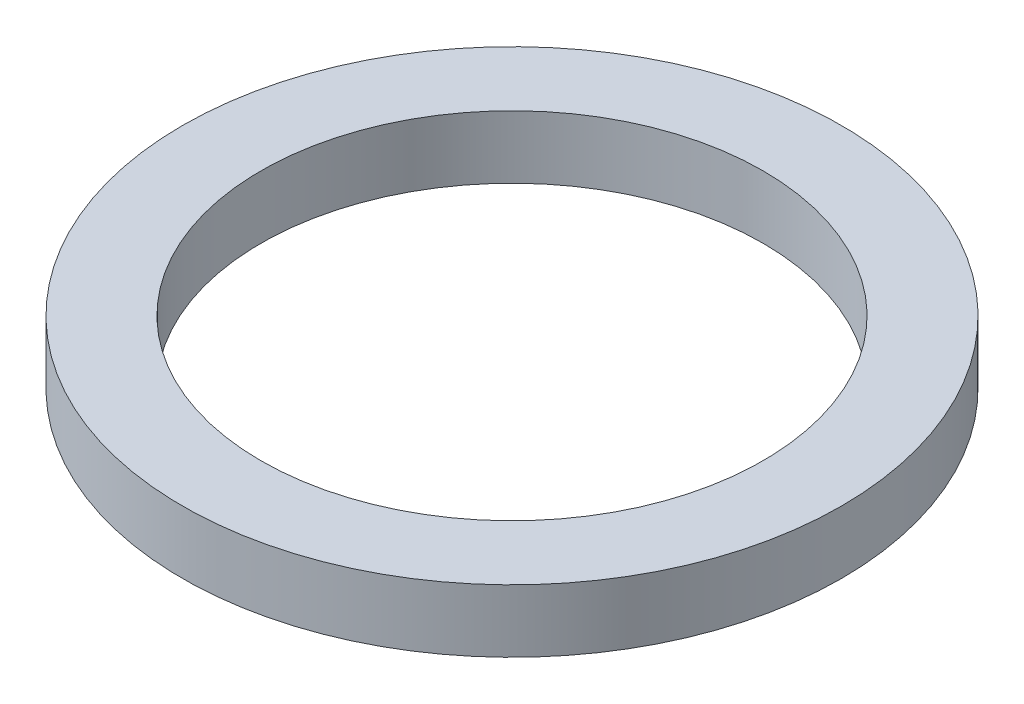
from build123d import *

# Parameters (mm, degrees)
SKETCH1_R           = 5.25
SKETCH1_R_2         = 4
EXTRUDE_THIN1_DEPTH = 1


with BuildPart() as part:
    # Sketch1 → Extrude-Thin1 (new body)
    with BuildSketch(Plane(origin=(0, 0, 0), x_dir=(1, 0, 0), z_dir=(0, 1, 0))):
        Circle(SKETCH1_R)
        Circle(SKETCH1_R_2, mode=Mode.SUBTRACT)
    extrude(amount=EXTRUDE_THIN1_DEPTH)


solid = part.part
